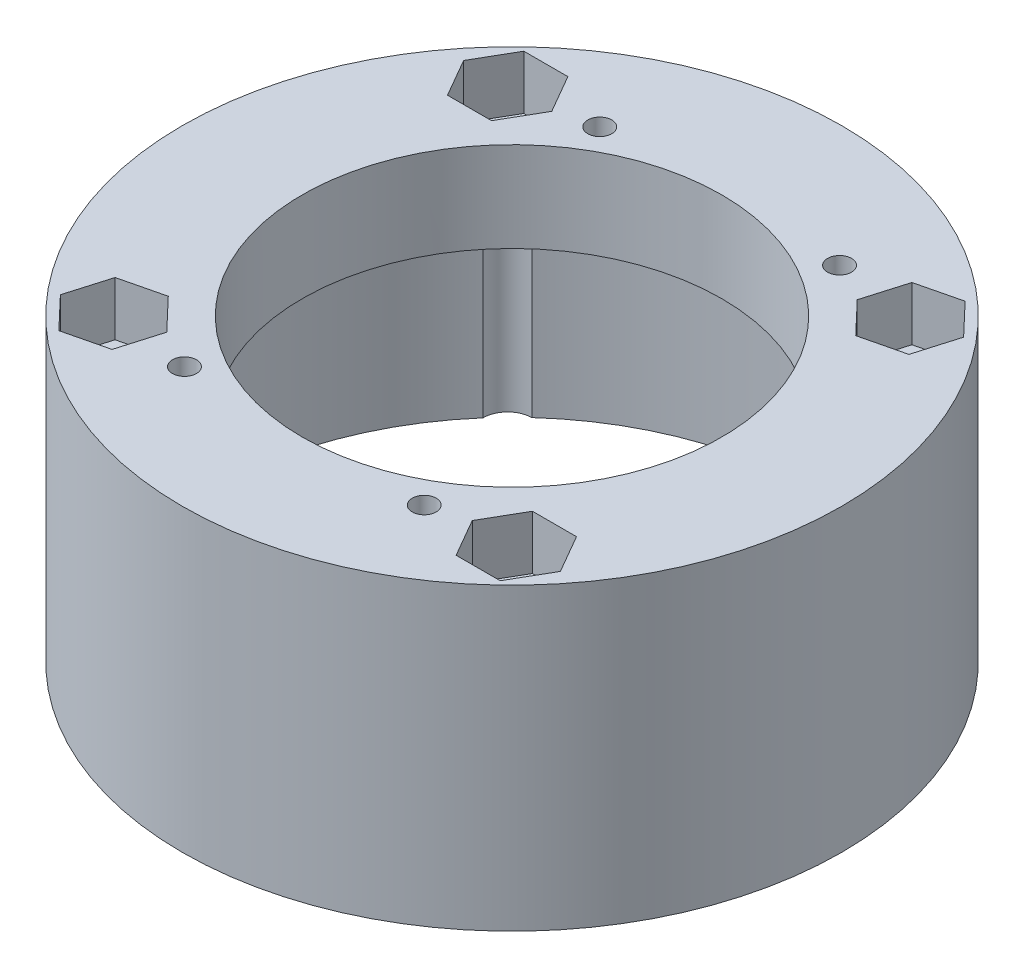
from build123d import *

# Parameters (mm, degrees)
SKETCH1_R           = 55
BOSS_EXTRUDE1_DEPTH = 40
SHELL1_T            = -5
SKETCH2_R           = 35
CUT_EXTRUDE1_DEPTH  = 86.293610546
SKETCH3_R           = 2
CUT_EXTRUDE2_DEPTH  = 88.464278423
BOSS_EXTRUDE2_START = 10
SKETCH4_R           = 55
SKETCH4_R_2         = 35
SKETCH4_R_3         = 4.1
SKETCH4_R_4         = 2
BOSS_EXTRUDE2_DEPTH = 10
SKETCH5_R           = 4.1
CUT_EXTRUDE3_DEPTH  = 93.466210045
CUT_EXTRUDE4_DEPTH  = 9


with BuildPart() as part:
    # Sketch1 → Boss-Extrude1 (new body)
    with BuildSketch(Plane(origin=(0, 0, 0), x_dir=(1, 0, 0), z_dir=(0, 1, 0))):
        with Locations(Location((0, 0, 0), (0, 0, 270))):
            Circle(SKETCH1_R)
    extrude(amount=BOSS_EXTRUDE1_DEPTH)

    # Shell1
    shell1_openings = [part.faces().sort_by_distance(p)[0] for p in [
        (0, 0, 0),
    ]]
    offset(amount=SHELL1_T, openings=shell1_openings, kind=Kind.INTERSECTION)

    # Sketch2 → Cut-Extrude1 (cut, through all)
    with BuildSketch(Plane.XZ.offset(-35)):
        with Locations(Location((0, 0, 0), (0, 0, 270))):
            Circle(SKETCH2_R)
    extrude(amount=-CUT_EXTRUDE1_DEPTH, mode=Mode.SUBTRACT)

    # Sketch3 → Cut-Extrude2 (cut, through all)
    with BuildSketch(Plane(origin=(0, 40, 0), x_dir=(1, 0, 0), z_dir=(0, 1, 0))):
        with Locations(Location((-20, -34.641016151, 0), (0, 0, 270))):
            Circle(SKETCH3_R)
        with Locations(Location((-20, 34.641016151, 0), (0, 0, 270))):
            Circle(SKETCH3_R)
        with Locations(Location((20, 34.641016151, 0), (0, 0, 270))):
            Circle(SKETCH3_R)
        with Locations(Location((20, -34.641016151, 0), (0, 0, 270))):
            Circle(SKETCH3_R)
    extrude(amount=-CUT_EXTRUDE2_DEPTH, mode=Mode.SUBTRACT)

    # Sketch4 → Boss-Extrude2 (add)
    with BuildSketch(Plane(origin=(0, 40, 0), x_dir=(1, 0, 0), z_dir=(0, 1, 0)).offset(BOSS_EXTRUDE2_START)):
        with Locations(Location((0, 0, 0), (0, 0, 270))):
            Circle(SKETCH4_R)
        with Locations(Location((0, 0, 0), (0, 0, 90))):
            Circle(SKETCH4_R_2, mode=Mode.SUBTRACT)
        with Locations(Location((-33.591727055, -32.872418126, 0), (0, 0, 270))):
            Circle(SKETCH4_R_3, mode=Mode.SUBTRACT)
        with Locations(Location((-33.591727055, 32.872418126, 0), (0, 0, 270))):
            Circle(SKETCH4_R_3, mode=Mode.SUBTRACT)
        with Locations(Location((33.591727055, 32.872418126, 0), (0, 0, 270))):
            Circle(SKETCH4_R_3, mode=Mode.SUBTRACT)
        with Locations(Location((33.591727055, -32.872418126, 0), (0, 0, 270))):
            Circle(SKETCH4_R_3, mode=Mode.SUBTRACT)
        with Locations(Location((20, 34.641016151, 0), (0, 0, 270))):
            Circle(SKETCH4_R_4, mode=Mode.SUBTRACT)
        with Locations(Location((20, -34.641016151, 0), (0, 0, 270))):
            Circle(SKETCH4_R_4, mode=Mode.SUBTRACT)
        with Locations(Location((-20, -34.641016151, 0), (0, 0, 270))):
            Circle(SKETCH4_R_4, mode=Mode.SUBTRACT)
        with Locations(Location((-20, 34.641016151, 0), (0, 0, 270))):
            Circle(SKETCH4_R_4, mode=Mode.SUBTRACT)
    extrude(amount=-BOSS_EXTRUDE2_DEPTH)

    # Sketch5 → Cut-Extrude3 (cut, through all)
    with BuildSketch(Plane(origin=(0, 50, 0), x_dir=(1, 0, 0), z_dir=(0, 1, 0))):
        with Locations(Location((-33.591727055, -32.872418126, 0), (0, 0, 179.732355429))):
            Circle(SKETCH5_R)
        with Locations(Location((-33.591727055, 32.872418126, 0), (0, 0, 90.972475399))):
            Circle(SKETCH5_R)
        with Locations(Location((33.591727055, 32.872418126, 0), (0, 0, 89.027524601))):
            Circle(SKETCH5_R)
        with Locations(Location((33.591727055, -32.872418126, 0), (0, 0, 0.267644571))):
            Circle(SKETCH5_R)
    extrude(amount=-CUT_EXTRUDE3_DEPTH, mode=Mode.SUBTRACT)

    # Sketch6 → Cut-Extrude4 (cut)
    with BuildSketch(Plane(origin=(0, 50, 0), x_dir=(1, 0, 0), z_dir=(0, 1, 0))):
        Polygon((37.266727055, -26.507131408), (29.916727055, -26.507131408), (26.241727055, -32.872418126), (29.916727055, -39.237704844), (37.266727055, -39.237704844), (40.941727055, -32.872418126), align=None)
        Polygon((-28.521851271, -38.19396485), (-26.448194513, -31.142550265), (-31.518070297, -25.821003541), (-38.661602839, -27.550871402), (-40.735259598, -34.602285987), (-35.665383814, -39.923832711), align=None)
        Polygon((-26.241727055, 32.872418126), (-29.916727055, 39.237704844), (-37.266727055, 39.237704844), (-40.941727055, 32.872418126), (-37.266727055, 26.507131408), (-29.916727055, 26.507131408), align=None)
        Polygon((31.518070297, 25.821003541), (38.661602839, 27.550871402), (40.735259598, 34.602285987), (35.665383814, 39.923832711), (28.521851271, 38.19396485), (26.448194513, 31.142550265), align=None)
    extrude(amount=-CUT_EXTRUDE4_DEPTH, mode=Mode.SUBTRACT)


solid = part.part
